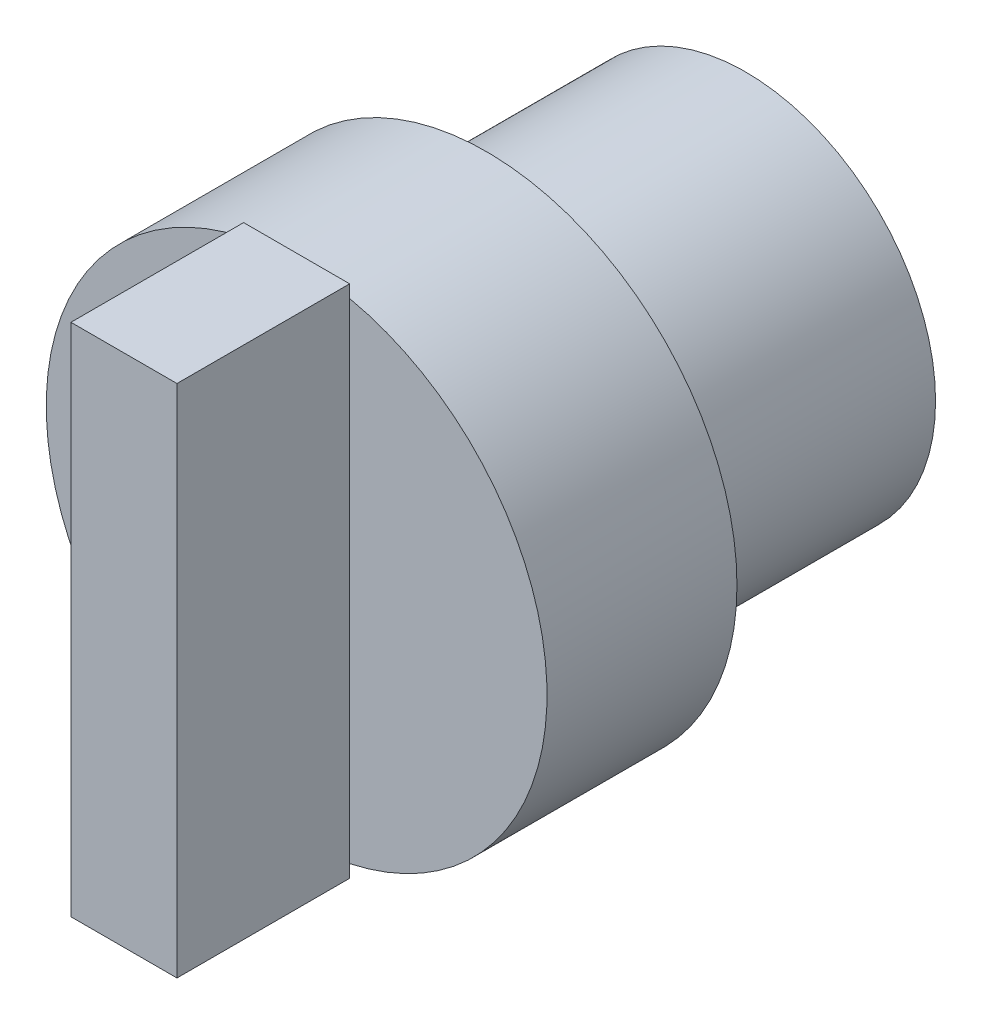
from build123d import *

# Parameters (mm, degrees)
SKETCH_1_R      = 11
EXTRUDE_1_DEPTH = 15
SKETCH_2_R      = 14.5
EXTRUDE_2_DEPTH = 11
SKETCH_3_W      = 6.140328376
SKETCH_3_H      = 29.814639278
EXTRUDE_3_DEPTH = 10


with BuildPart() as part:
    # 草图1 → 凸台-拉伸1 (new body)
    with BuildSketch(Plane.XY):
        Circle(SKETCH_1_R)
    extrude(amount=EXTRUDE_1_DEPTH)

    # 草图2 → 凸台-拉伸2 (add)
    with BuildSketch(Plane.XY.offset(15)):
        Circle(SKETCH_2_R)
    extrude(amount=EXTRUDE_2_DEPTH)

    # 草图3 → 凸台-拉伸3 (add)
    with BuildSketch(Plane.XY.offset(26)):
        Rectangle(SKETCH_3_W, SKETCH_3_H)
    extrude(amount=EXTRUDE_3_DEPTH)


solid = part.part
